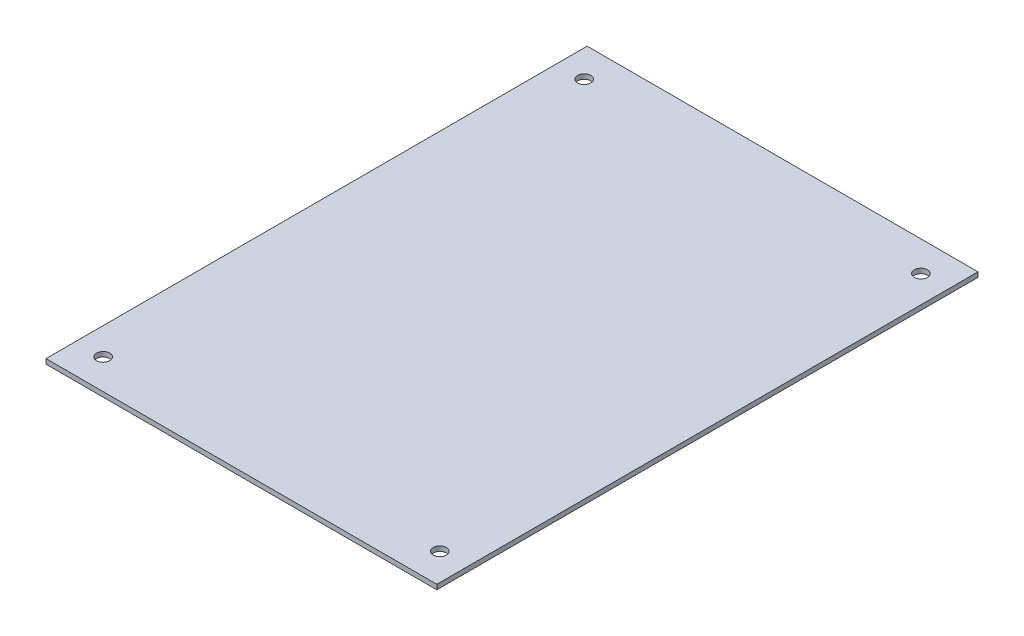
from build123d import *

# Parameters (mm, degrees)
SKETCH1_W           = 65
SKETCH1_H           = 90
SKETCH1_R           = 1.1
BOSS_EXTRUDE1_DEPTH = 0.8


with BuildPart() as part:
    # Sketch1 → Boss-Extrude1 (new body)
    with BuildSketch(Plane(origin=(0, 0, 0), x_dir=(1, 0, 0), z_dir=(0, 1, 0))):
        with Locations((32.5, 45)):
            Rectangle(SKETCH1_W, SKETCH1_H)
        with Locations((60.5, 85)):
            Circle(SKETCH1_R, mode=Mode.SUBTRACT)
        with Locations((4.5, 85)):
            Circle(SKETCH1_R, mode=Mode.SUBTRACT)
        with Locations((4.5, 5)):
            Circle(SKETCH1_R, mode=Mode.SUBTRACT)
        with Locations((60.5, 5)):
            Circle(SKETCH1_R, mode=Mode.SUBTRACT)
    extrude(amount=BOSS_EXTRUDE1_DEPTH)


solid = part.part
